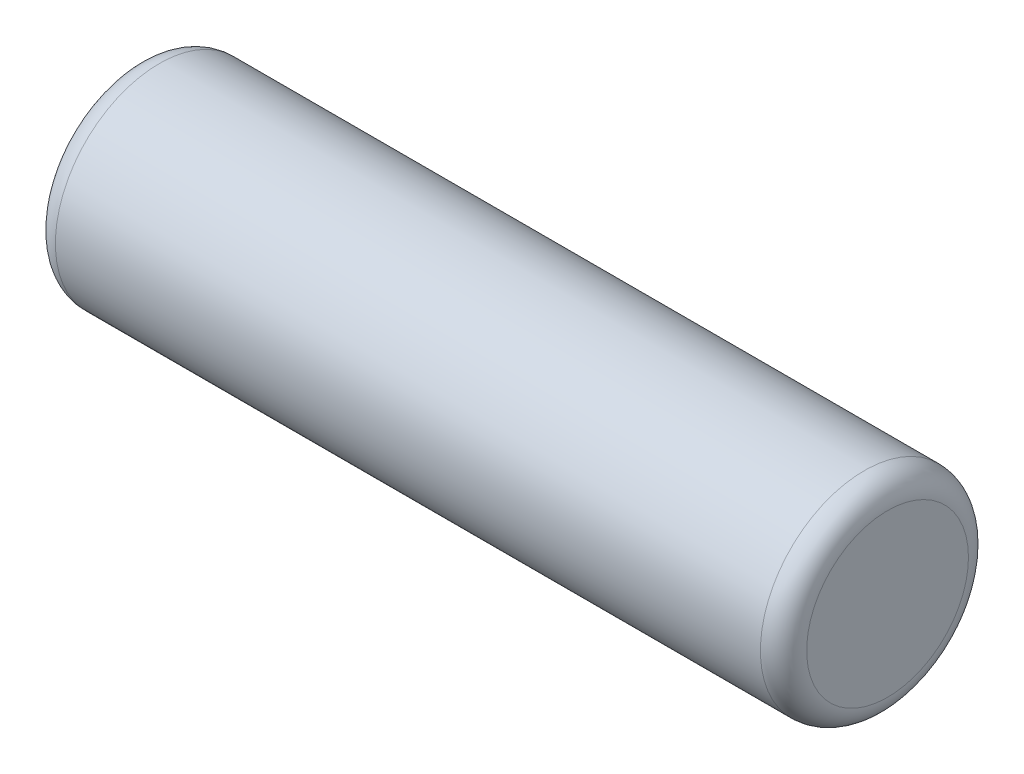
from build123d import *

# Parameters (mm, degrees)
SKETCH1_R           = 9
BOSS_EXTRUDE1_DEPTH = 32.5
FILLET1_R           = 2


with BuildPart() as part:
    # Sketch1 → Boss-Extrude1 (new body, symmetric)
    with BuildSketch(Plane(origin=(0, 0, 0), x_dir=(0, 0, -1), z_dir=(1, 0, 0))):
        Circle(SKETCH1_R)
    extrude(amount=BOSS_EXTRUDE1_DEPTH, both=True)

    # Fillet1
    fillet1_edges = [part.edges().sort_by_distance(p)[0] for p in [
        (-32.5, 0, 9),
        (32.5, 0, 9),
    ]]
    fillet(fillet1_edges, radius=FILLET1_R)


solid = part.part
